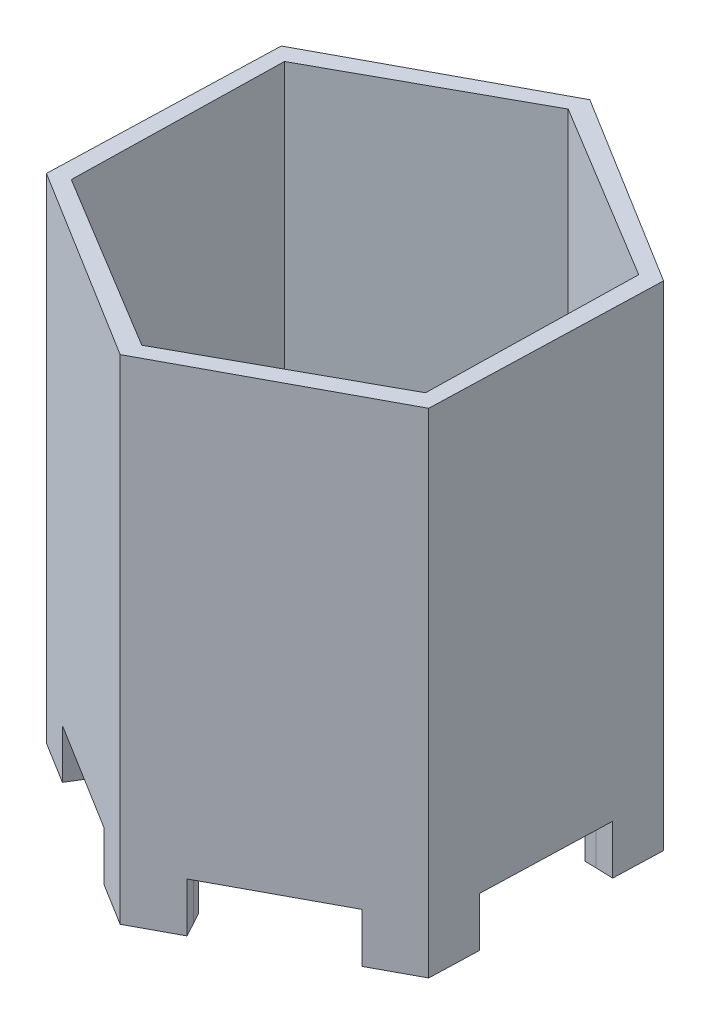
from build123d import *

# Parameters (mm, degrees)
BODY_DEPTH                 = 150
BOT_PLATE_DEPTH            = 10
SKETCH8_W                  = 39.282032303
SKETCH8_H                  = 15
LEG_1_DEPTH                = 122.011417136
SKETCH9_W                  = 39.282032302
SKETCH9_H                  = 15
LEG_2_DEPTH                = 125.337209756
SKETCH10_W                 = 39.282032303
SKETCH10_H                 = 15
LEG_3_DEPTH                = 120.609235759
F_9_0_196_DIAMETER_HOLE1_D = 4.9784
CUT_EXTRUDE1_DEPTH         = 1
BOSS_EXTRUDE5_DEPTH        = 20
BOSS_EXTRUDE7_DEPTH        = 20
BOSS_EXTRUDE8_DEPTH        = 20
BOSS_EXTRUDE9_DEPTH        = 20
BOSS_EXTRUDE10_DEPTH       = 20
BOSS_EXTRUDE11_DEPTH       = 20


with BuildPart() as part:
    # Sketch3 → body (new body)
    with BuildSketch(Plane(origin=(0, 0, 0), x_dir=(1, 0, 0), z_dir=(0, 1, 0))):
        Polygon((-26.246840152, 20.064679688), (-24.100311768, 89.313451633), (-82.998243261, 125.796785716), (-144.042703139, 93.031347854), (-146.189231523, 23.782575909), (-87.291300029, -12.700758174), align=None)
        Polygon((-30.815459537, 23.659426401), (-29.497763434, 87.154284541), (-83.827075542, 120.042871912), (-139.474083753, 89.436601141), (-140.791779857, 25.941743001), (-86.462467749, -6.94684437), align=None, mode=Mode.SUBTRACT)
    extrude(amount=BODY_DEPTH)

    # Sketch7 → bot plate (add)
    with BuildSketch(Plane(origin=(0, 20, 0), x_dir=(1, 0, 0), z_dir=(0, 1, 0))):
        Polygon((-30.815459537, 23.659426401), (-29.497763434, 87.154284541), (-83.827075542, 120.042871912), (-139.474083753, 89.436601141), (-140.791779857, 25.941743001), (-86.462467749, -6.94684437), align=None)
    extrude(amount=BOT_PLATE_DEPTH)

    # Sketch8 → leg 1 (cut)
    with BuildSketch(Plane(origin=(33.299538635, 0, -53.758078711), x_dir=(-0.850118415, 0, -0.526591569), z_dir=(0.526591569, 0, -0.850118415))):
        with Locations((102.160845609, 7.5)):
            Rectangle(SKETCH8_W, SKETCH8_H)
    extrude(amount=-LEG_1_DEPTH, mode=Mode.SUBTRACT)

    # Sketch9 → leg 2 (cut)
    with BuildSketch(Plane(origin=(-26.843000328, 0, -0.832061862), x_dir=(0.030982469, 0, -0.999519928), z_dir=(0.999519928, 0, 0.030982469))):
        with Locations((53.882871452, 7.5)):
            Rectangle(SKETCH9_W, SKETCH9_H)
    extrude(amount=-LEG_2_DEPTH, mode=Mode.SUBTRACT)

    # Sketch10 → leg 3 (cut)
    with BuildSketch(Plane(origin=(-70.982707514, 0, -132.246089891), x_dir=(-0.881100884, 0, 0.472928359), z_dir=(-0.472928359, 0, -0.881100884))):
        with Locations((48.277974157, 7.5)):
            Rectangle(SKETCH10_W, SKETCH10_H)
    extrude(amount=-LEG_3_DEPTH, mode=Mode.SUBTRACT)

    # #9 (0.196) Diameter Hole1 (through all)
    with Locations(Plane(origin=(0, 30, 0), x_dir=(1, 0, 0), z_dir=(0, 1, 0))):
        with Locations((-85.144878353, 56.542871912), (-85.898995371, 88.360548004), (-85.144878353, 24.80315563), (-112.654678449, 56.355962139), (-57.635318965, 56.718182868), (-112.654678449, 88.34266323), (-112.654678449, 24.80315563), (-57.635318965, 24.80315563), (-57.635318965, 88.34266323), (-98.564032754, 72.627746926), (-71.058033186, 72.631523432), (-71.058033186, 40.682224825), (-98.564032754, 40.682224825), (-130.2290882, 72.627746926), (-130.2290882, 40.682224825), (-40.178126006, 40.682224825), (-40.178126006, 72.631523432), (-85.144878353, 8.356291016), (-85.604508946, 106.005680317)):
            Hole(F_9_0_196_DIAMETER_HOLE1_D / 2)

    # Sketch24 → Cut-Extrude1 (cut)
    with BuildSketch(Plane(origin=(-70.982707514, 0, -132.246089891), x_dir=(-0.881100884, 0, 0.472928359), z_dir=(-0.472928359, 0, -0.881100884))):
        Polygon((37.901855727, 33.412733714), (38.226475118, 33.412733714), (38.911471112, 30.845926823), (39.93020108, 33.412733714), (39.975773997, 33.412733714), (40.975573676, 30.863454868), (41.664075279, 33.412733714), (41.985189061, 33.412733714), (41.041479125, 29.912733714), (40.99660733, 29.912733714), (39.943522394, 32.589616727), (38.877817266, 29.912733714), (38.832945471, 29.912733714), align=None)
        Polygon((42.613394189, 33.412733714), (42.927496753, 33.412733714), (42.927496753, 30.271708073), (44.273650599, 30.271708073), (44.273650599, 29.912733714), (42.613394189, 29.912733714), align=None)
        with BuildLine():
            Line((48.132624958, 32.815377945), (47.863394189, 32.560169611))
            add(Edge.make_bspline(
                [(47.863394189, 32.560169611), (47.814675301, 32.606000474), (47.718399254, 32.696569337), (47.561439012, 32.814080332), (47.397675378, 32.914746433), (47.227962881, 32.996652669), (47.056504327, 33.06200543), (46.885575551, 33.10853357), (46.716929849, 33.138206107), (46.604762631, 33.141754477), (46.549491945, 33.143502945)],
                knots=[0, 0, 0, 0, 0.000200536, 0.000396289, 0.000586999, 0.000776397, 0.000960787, 0.001136655, 0.001307246, 0.001472961, 0.001472961, 0.001472961, 0.001472961], degree=3))
            add(Edge.make_bspline(
                [(46.549491945, 33.143502945), (46.515577245, 33.143089339), (46.447835805, 33.1422632), (46.347213861, 33.131718984), (46.247647224, 33.11655412), (46.149323849, 33.094612243), (46.052052563, 33.066803183), (45.95617167, 33.03201772), (45.861502316, 32.991462476), (45.768936235, 32.944600002), (45.679195731, 32.893120156), (45.594438895, 32.836071615), (45.514125497, 32.775282825), (45.439765071, 32.709231846), (45.370929885, 32.63851698), (45.305981513, 32.564453674), (45.247204217, 32.485018456), (45.194113052, 32.40167283), (45.146751433, 32.31588064), (45.10494278, 32.228467651), (45.069845692, 32.139723796), (45.042076236, 32.049537719), (45.019165583, 31.958607129), (45.003047975, 31.866302408), (44.993961253, 31.772524723), (44.992389473, 31.709727464), (44.991599317, 31.678158393)],
                knots=[0, 0, 0, 0, 0.000101701, 0.000203139, 0.000303193, 0.000403728, 0.000505139, 0.000606491, 0.000709509, 0.000813922, 0.000917583, 0.001019673, 0.001120217, 0.001219549, 0.001317716, 0.001416124, 0.001514842, 0.00161384, 0.001712379, 0.001808658, 0.001904353, 0.001998376, 0.002091562, 0.002185504, 0.002279198, 0.002373914, 0.002373914, 0.002373914, 0.002373914], degree=3))
            add(Edge.make_bspline(
                [(44.991599317, 31.678158393), (44.992355035, 31.645887576), (44.993864408, 31.581434063), (45.003524728, 31.48523999), (45.021452968, 31.390474588), (45.045420677, 31.296826455), (45.075401493, 31.204135207), (45.112774159, 31.112802697), (45.15703976, 31.022832306), (45.208276312, 30.935034689), (45.264462515, 30.849511665), (45.327405596, 30.768952144), (45.394266179, 30.692283366), (45.467480079, 30.621207602), (45.544699622, 30.553823706), (45.628231898, 30.491988184), (45.716434358, 30.434509961), (45.80944157, 30.382113442), (45.906244352, 30.335304906), (46.005501105, 30.29368101), (46.107528921, 30.259401673), (46.211791611, 30.231463569), (46.318164882, 30.208563271), (46.427188685, 30.193830791), (46.538061393, 30.18313996), (46.612800026, 30.18235829), (46.650453484, 30.181964483)],
                knots=[0, 0, 0, 0, 9.6818e-05, 0.000193372, 0.000289633, 0.000385881, 0.000483216, 0.000581645, 0.00068167, 0.000783767, 0.00088644, 0.000988395, 0.001090231, 0.001191373, 0.001294266, 0.001397472, 0.001502873, 0.001609927, 0.001717482, 0.001825293, 0.001932604, 0.002040093, 0.002149, 0.002258763, 0.002369974, 0.002482889, 0.002482889, 0.002482889, 0.002482889], degree=3))
            add(Edge.make_bspline(
                [(46.650453484, 30.181964483), (46.695831831, 30.182913059), (46.784939588, 30.184775743), (46.915926031, 30.199276033), (47.041729102, 30.221922826), (47.161995305, 30.255088723), (47.276864326, 30.297392398), (47.386757267, 30.348387784), (47.490808926, 30.410030843), (47.589332099, 30.479604711), (47.680089285, 30.557119543), (47.761943409, 30.640763998), (47.833588898, 30.730132065), (47.896093597, 30.82469738), (47.947802252, 30.925242685), (47.990245047, 31.031275248), (48.022778338, 31.14284276), (48.036133313, 31.219934391), (48.042881368, 31.25888756)],
                knots=[0, 0, 0, 0, 0.000136106, 0.000267267, 0.000394882, 0.00051922, 0.000641, 0.000761758, 0.000882124, 0.001003321, 0.001123172, 0.001239687, 0.001353892, 0.00146629, 0.00157918, 0.001692449, 0.001808499, 0.001927028, 0.001927028, 0.001927028, 0.001927028], degree=3))
            Line((48.042881368, 31.25888756), (46.876214702, 31.25888756))
            Line((46.876214702, 31.25888756), (46.876214702, 31.617861919))
            Line((46.876214702, 31.617861919), (48.356983933, 31.617861919))
            add(Edge.make_bspline(
                [(48.356983933, 31.617861919), (48.355278084, 31.55095443), (48.351939431, 31.420004388), (48.328520515, 31.229034118), (48.290704003, 31.048662424), (48.239043691, 30.878699353), (48.172168411, 30.71938576), (48.090795882, 30.570559894), (47.993623761, 30.433183213), (47.88411332, 30.306134209), (47.761213362, 30.192804997), (47.628244742, 30.093199059), (47.484987774, 30.009296444), (47.331577966, 29.941035781), (47.168517533, 29.887761787), (46.995429153, 29.84999021), (46.812547552, 29.827360246), (46.687210875, 29.824468867), (46.623109734, 29.822990124)],
                knots=[0, 0, 0, 0, 0.000200697, 0.000392801, 0.000576238, 0.000752994, 0.000924878, 0.001093697, 0.001260784, 0.001428776, 0.001595974, 0.001761299, 0.001926279, 0.002092931, 0.002264096, 0.002439994, 0.002623661, 0.002815923, 0.002815923, 0.002815923, 0.002815923], degree=3))
            add(Edge.make_bspline(
                [(46.623109734, 29.822990124), (46.583599598, 29.823559245), (46.505672878, 29.824681736), (46.39058195, 29.832659083), (46.278664329, 29.84493966), (46.16993632, 29.863484783), (46.063997978, 29.886199437), (45.961378393, 29.915286156), (45.861686651, 29.948954855), (45.764768665, 29.987250529), (45.671504119, 30.031622186), (45.581477602, 30.080931825), (45.494191476, 30.134925186), (45.410240311, 30.194536032), (45.329186689, 30.259318492), (45.251553246, 30.329402411), (45.176905368, 30.40457353), (45.130144904, 30.45795254), (45.106583292, 30.484849099)],
                knots=[0, 0, 0, 0, 0.000118523, 0.000233765, 0.000345956, 0.000456148, 0.000564516, 0.000670839, 0.000775933, 0.000880089, 0.000983271, 0.001085557, 0.001187895, 0.001290998, 0.001394253, 0.001499002, 0.001604602, 0.001711853, 0.001711853, 0.001711853, 0.001711853], degree=3))
            add(Edge.make_bspline(
                [(45.106583292, 30.484849099), (45.07239736, 30.527519752), (45.004592947, 30.612152769), (44.91731479, 30.747752713), (44.842913388, 30.888154573), (44.782545565, 31.033749202), (44.735407479, 31.184400415), (44.701601226, 31.339915706), (44.681793937, 31.500495336), (44.6789404, 31.609160601), (44.677496753, 31.664135958)],
                knots=[0, 0, 0, 0, 0.00016394, 0.000325158, 0.000482912, 0.000640071, 0.000797293, 0.000955853, 0.00111691, 0.001281823, 0.001281823, 0.001281823, 0.001281823], degree=3))
            add(Edge.make_bspline(
                [(44.677496753, 31.664135958), (44.678028991, 31.70530221), (44.679086703, 31.787111518), (44.691912219, 31.908568825), (44.710313637, 32.027869517), (44.737360692, 32.144916074), (44.771456957, 32.259786665), (44.814010443, 32.372534629), (44.863555339, 32.483226501), (44.921140835, 32.591100369), (44.985225294, 32.694724782), (45.054775514, 32.793682585), (45.130779115, 32.88617165), (45.211994914, 32.973363298), (45.299391904, 33.054162145), (45.392151328, 33.129316256), (45.490344671, 33.198926442), (45.594280851, 33.261896276), (45.702408535, 33.318459897), (45.814468537, 33.368049109), (45.930426648, 33.409032424), (46.049414125, 33.443806204), (46.172331626, 33.469521344), (46.298287163, 33.48817009), (46.427937275, 33.500930689), (46.515573304, 33.501956945), (46.560008772, 33.502477304)],
                knots=[0, 0, 0, 0, 0.000123447, 0.000245326, 0.00036601, 0.000485407, 0.000605413, 0.000725221, 0.000846669, 0.000968994, 0.001091771, 0.00121199, 0.001331568, 0.001450618, 0.001569191, 0.001688326, 0.001808545, 0.001929991, 0.002052609, 0.002174413, 0.002297271, 0.002421315, 0.002546037, 0.002673651, 0.002803207, 0.002936466, 0.002936466, 0.002936466, 0.002936466], degree=3))
            add(Edge.make_bspline(
                [(46.560008772, 33.502477304), (46.596247016, 33.501897812), (46.668103195, 33.500748748), (46.775028927, 33.4927841), (46.880301942, 33.480160219), (46.984078332, 33.462933432), (47.086004698, 33.439469742), (47.186371403, 33.411391457), (47.285323939, 33.378699634), (47.382552189, 33.339710788), (47.478709905, 33.295457163), (47.574331745, 33.245643741), (47.669090991, 33.189418736), (47.763151973, 33.126615201), (47.85710783, 33.058311783), (47.949472473, 32.982554959), (48.042475417, 32.902332203), (48.102277231, 32.844650019), (48.132624958, 32.815377945)],
                knots=[0, 0, 0, 0, 0.00010871, 0.000215559, 0.000321482, 0.000426718, 0.00053098, 0.000635089, 0.000739295, 0.000843451, 0.000949174, 0.001056739, 0.001166761, 0.001279546, 0.001395941, 0.001515076, 0.00163782, 0.001764288, 0.001764288, 0.001764288, 0.001764288], degree=3))
        make_face()
        Polygon((48.805701881, 33.412733714), (49.165377362, 33.412733714), (50.085249157, 31.908827464), (51.003718708, 33.412733714), (51.363394189, 33.412733714), (50.241599317, 31.576495733), (50.241599317, 29.912733714), (49.927496753, 29.912733714), (49.927496753, 31.576495733), align=None)
        Polygon((51.991599317, 33.412733714), (52.305701881, 33.412733714), (52.305701881, 30.271708073), (53.651855727, 30.271708073), (53.651855727, 29.912733714), (51.991599317, 29.912733714), align=None)
        with BuildLine():
            Line((40.728778804, 23.079400381), (40.728778804, 26.66914397))
            Line((40.728778804, 26.66914397), (41.042881368, 26.66914397))
            Line((41.042881368, 26.66914397), (41.042881368, 25.17295006))
            add(Edge.make_bspline(
                [(41.042881368, 25.17295006), (41.078274787, 25.213707992), (41.147328807, 25.293228397), (41.263105258, 25.397076047), (41.384510828, 25.485128524), (41.512469084, 25.557714643), (41.647162017, 25.61298825), (41.787894125, 25.65341064), (41.935025166, 25.677797543), (42.03534434, 25.680563616), (42.086150599, 25.681964483)],
                knots=[0, 0, 0, 0, 0.000161815, 0.000315708, 0.000465351, 0.000611017, 0.000755934, 0.000901068, 0.001049529, 0.001201867, 0.001201867, 0.001201867, 0.001201867], degree=3))
            add(Edge.make_bspline(
                [(42.086150599, 25.681964483), (42.131316737, 25.680724255), (42.220617889, 25.678272113), (42.351900036, 25.659637617), (42.478213311, 25.629419815), (42.599488959, 25.587527636), (42.715161092, 25.531944659), (42.826220149, 25.465403351), (42.932097133, 25.386165022), (43.031152019, 25.295566711), (43.122445905, 25.197210088), (43.202358415, 25.092029773), (43.269858111, 24.981554682), (43.325689404, 24.86615462), (43.368860457, 24.745358269), (43.398602724, 24.61928407), (43.417496188, 24.488056052), (43.419876434, 24.398743248), (43.421086497, 24.353338682)],
                knots=[0, 0, 0, 0, 0.000135464, 0.000267835, 0.000396906, 0.000524625, 0.000651952, 0.000781211, 0.000912462, 0.00104796, 0.001183414, 0.001314526, 0.001443549, 0.001571179, 0.00169847, 0.001827542, 0.001959218, 0.002095382, 0.002095382, 0.002095382, 0.002095382], degree=3))
            add(Edge.make_bspline(
                [(43.421086497, 24.353338682), (43.419850056, 24.308638664), (43.41741199, 24.220497269), (43.398790682, 24.090790713), (43.368044417, 23.965952014), (43.324083234, 23.846303756), (43.268818295, 23.731283843), (43.19970702, 23.622203439), (43.11989602, 23.517164463), (43.027564872, 23.419540832), (42.927651319, 23.329307432), (42.820737076, 23.250901566), (42.709515154, 23.183184446), (42.592252042, 23.129528999), (42.470684001, 23.086128077), (42.343508614, 23.056010387), (42.211445386, 23.038437332), (42.121726497, 23.035841765), (42.076334894, 23.034528586)],
                knots=[0, 0, 0, 0, 0.000134063, 0.000264351, 0.000392226, 0.000519096, 0.000646094, 0.000774294, 0.000905831, 0.001041249, 0.001176798, 0.001309174, 0.001438434, 0.001566731, 0.001695345, 0.001825098, 0.001958069, 0.002094233, 0.002094233, 0.002094233, 0.002094233], degree=3))
            add(Edge.make_bspline(
                [(42.076334894, 23.034528586), (42.024369782, 23.035969194), (41.922475257, 23.038793976), (41.773422592, 23.062212955), (41.632341043, 23.102074565), (41.497623494, 23.155636321), (41.371195771, 23.228164975), (41.252255189, 23.318121725), (41.141551816, 23.426988862), (41.076335001, 23.510050351), (41.042881368, 23.552657592)],
                knots=[0, 0, 0, 0, 0.00015584, 0.000305575, 0.000451192, 0.000594929, 0.000739376, 0.000887033, 0.001041224, 0.001203621, 0.001203621, 0.001203621, 0.001203621], degree=3))
            Line((41.042881368, 23.552657592), (41.042881368, 23.079400381))
            Line((41.042881368, 23.079400381), (40.728778804, 23.079400381))
        make_face()
        with BuildLine():
            add(Edge.make_bspline(
                [(42.073530407, 23.34863115), (42.119444759, 23.350264779), (42.210072388, 23.353489302), (42.343116179, 23.378662925), (42.470430388, 23.420547039), (42.59137347, 23.477830748), (42.704052782, 23.549852782), (42.804705416, 23.636998953), (42.894185126, 23.736500468), (42.968836902, 23.848734161), (43.031163146, 23.96818513), (43.073976423, 24.093839431), (43.102696144, 24.22233422), (43.105548442, 24.309480265), (43.106983933, 24.353338682)],
                knots=[0, 0, 0, 0, 0.000137677, 0.000271753, 0.000404561, 0.000538791, 0.000672205, 0.000804452, 0.00093703, 0.001072374, 0.001207834, 0.001339988, 0.001469657, 0.001601037, 0.001601037, 0.001601037, 0.001601037], degree=3))
            add(Edge.make_bspline(
                [(43.106983933, 24.353338682), (43.105096189, 24.397154224), (43.101328237, 24.484610385), (43.074953455, 24.614260052), (43.028895665, 24.739847677), (42.967777642, 24.861025665), (42.891909656, 24.974033466), (42.802903693, 25.075523593), (42.701021887, 25.163083577), (42.588198467, 25.236073648), (42.468018277, 25.295633201), (42.341527643, 25.336478226), (42.21136952, 25.363216414), (42.122974027, 25.366305542), (42.078438259, 25.367861919)],
                knots=[0, 0, 0, 0, 0.000131426, 0.000262328, 0.000394949, 0.000531659, 0.000668557, 0.000802185, 0.00093542, 0.001070185, 0.001204391, 0.001336533, 0.001467986, 0.001601464, 0.001601464, 0.001601464, 0.001601464], degree=3))
            add(Edge.make_bspline(
                [(42.078438259, 25.367861919), (42.032970752, 25.366306422), (41.942726976, 25.363219075), (41.809558753, 25.336431251), (41.67949547, 25.295383639), (41.555207938, 25.23645229), (41.439353882, 25.164340829), (41.33574127, 25.07960063), (41.246409712, 24.982820722), (41.172865942, 24.87431492), (41.114461143, 24.757129885), (41.072677395, 24.632117681), (41.047677748, 24.499936369), (41.044499616, 24.409303163), (41.042881368, 24.363154387)],
                knots=[0, 0, 0, 0, 0.000136278, 0.000270483, 0.00040596, 0.000544592, 0.000681933, 0.000814436, 0.000944937, 0.001075619, 0.00120637, 0.001336516, 0.001469903, 0.00160828, 0.00160828, 0.00160828, 0.00160828], degree=3))
            add(Edge.make_bspline(
                [(41.042881368, 24.363154387), (41.043841039, 24.327816569), (41.045729974, 24.258260559), (41.060160343, 24.156132868), (41.083116004, 24.058399776), (41.115459498, 23.964954781), (41.157960733, 23.876328341), (41.209170999, 23.791832261), (41.270122645, 23.712228983), (41.339029235, 23.637713662), (41.414991615, 23.569904248), (41.496514734, 23.511126023), (41.581932665, 23.460511833), (41.672222636, 23.42016699), (41.766333926, 23.387240469), (41.865232267, 23.365506724), (41.967903692, 23.350531685), (42.037950789, 23.349271332), (42.073530407, 23.34863115)],
                knots=[0, 0, 0, 0, 0.000105983, 0.000208608, 0.000308773, 0.00040678, 0.000504626, 0.000603105, 0.000702667, 0.000804872, 0.000907174, 0.001007588, 0.001105951, 0.001204477, 0.001303809, 0.001404498, 0.001507818, 0.001614471, 0.001614471, 0.001614471, 0.001614471], degree=3))
        make_face(mode=Mode.SUBTRACT)
        Polygon((43.780060856, 25.637092688), (44.118702683, 25.637092688), (44.984588099, 23.678158393), (45.86379483, 25.637092688), (46.203137779, 25.637092688), (44.632624958, 22.137092688), (44.293282009, 22.137092688), (44.814215503, 23.297449259), align=None)
        Polygon((48.042881368, 26.579400381), (48.356983933, 26.579400381), (48.356983933, 25.143502945), (50.151855727, 25.143502945), (50.151855727, 26.579400381), (50.465958292, 26.579400381), (50.465958292, 23.079400381), (50.151855727, 23.079400381), (50.151855727, 24.784528586), (48.356983933, 24.784528586), (48.356983933, 23.079400381), (48.042881368, 23.079400381), align=None)
    extrude(amount=-CUT_EXTRUDE1_DEPTH, mode=Mode.SUBTRACT)

    # Sketch26 → Boss-Extrude5 (add)
    with BuildSketch(Plane.XZ.offset(-20)):
        Polygon((-97.305747097, 0.3827977), (-86.462467749, 6.94684437), (-76.342967093, 1.381043313), (-78.194380894, -1.985117816), (-86.462467749, 2.562391802), (-95.508489719, -2.586127536), align=None)
    extrude(amount=BOSS_EXTRUDE5_DEPTH)

    # Sketch30 → Boss-Extrude7 (add)
    with BuildSketch(Plane.XZ.offset(-20)):
        Polygon((-41.860444867, -17.538732936), (-30.756306981, -23.651141425), (-30.520712315, -35.197869536), (-34.361627856, -35.276237989), (-34.554119287, -25.842042156), (-43.534042238, -20.57908209), align=None)
    extrude(amount=BOSS_EXTRUDE7_DEPTH)

    # Sketch31 → Boss-Extrude8 (add)
    with BuildSketch(Plane.XZ.offset(-20)):
        Polygon((-29.760423455, -74.48554208), (-29.497431962, -87.158120791), (-39.377307397, -93.138964904), (-41.366781547, -89.852512956), (-33.294479267, -84.965894507), (-33.23021682, -74.557550009), align=None)
    extrude(amount=BOSS_EXTRUDE8_DEPTH)

    # Sketch32 → Boss-Extrude9 (add)
    with BuildSketch(Plane.XZ.offset(-20)):
        Polygon((-140.576246067, -38.613998875), (-140.839237561, -25.941420165), (-130.959362125, -19.960576052), (-128.969887975, -23.247028), (-137.042190255, -28.133646449), (-137.106452702, -38.541990947), align=None)
    extrude(amount=BOSS_EXTRUDE9_DEPTH)

    # Sketch36 → Boss-Extrude10 (add)
    with BuildSketch(Plane.XZ.offset(-20)):
        Polygon((-72.982426188, -113.501141755), (-83.825705536, -120.065188425), (-93.945206191, -114.499387368), (-92.093792391, -111.133226239), (-83.825705536, -115.680735857), (-74.779683565, -110.532216519), align=None)
    extrude(amount=BOSS_EXTRUDE10_DEPTH)

    # Sketch37 → Boss-Extrude11 (add)
    with BuildSketch(Plane.XZ.offset(-20)):
        Polygon((-128.429170958, -95.562630822), (-139.533308843, -89.450222333), (-139.768903509, -77.903494222), (-135.927987968, -77.825125769), (-135.735496538, -87.259321602), (-126.755573587, -92.522281668), align=None)
    extrude(amount=BOSS_EXTRUDE11_DEPTH)


solid = part.part
